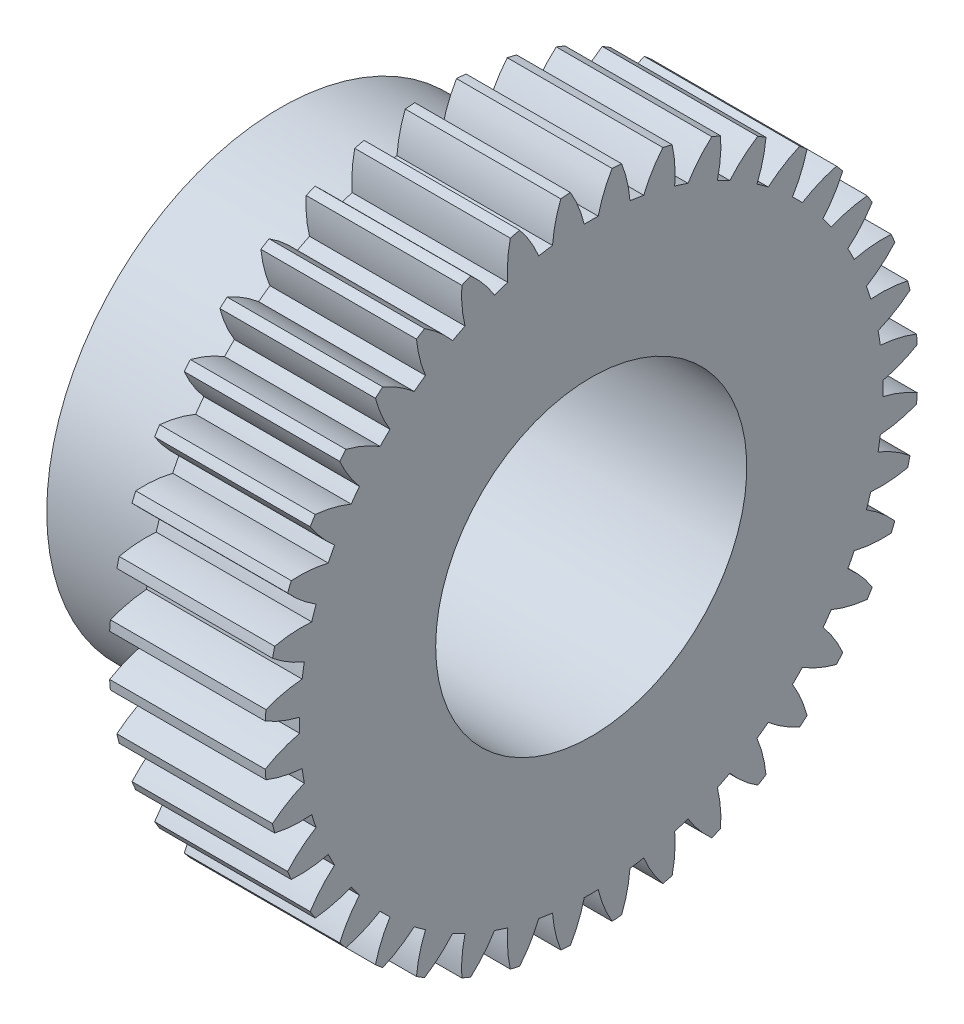
from build123d import *

# Parameters (mm, degrees)
BASPROSKE_W         = 10
BASPROSKE_H         = 21
TOOTHCUT_DEPTH      = 32.336879232
TEETHCUTS_COUNT     = 40
TEETHCUTS_ANGLE     = 351
HUBNEAONESKE_R      = 15
HUBNEARONE_DEPTH    = 40.0000508
BORSKE_R            = 10
BORE_DEPTH          = 10.0000508
SKETCH_1_R          = 32.883297891
CUT_EXTRUDE_1_DEPTH = 43.171205755


with BuildPart() as part:
    # BasProSke → Base-Revolve (revolve)
    with BuildSketch(Plane(origin=(0, 0, 0), x_dir=(1, 0, 0), z_dir=(0, 1, 0)), mode=Mode.PRIVATE) as base_revolve_sk:
        with Locations((5, 10.5)):
            Rectangle(BASPROSKE_W, BASPROSKE_H)
    revolve(base_revolve_sk.sketch.rotate(Axis((-10, 0, 0), (1, 0, 0)), 180), axis=Axis((-10, 0, 0), (1, 0, 0)))

    # TooCutSke → ToothCut (cut, through all)
    with BuildSketch(Plane(origin=(0, 0, 0), x_dir=(0, 0, -1), z_dir=(1, 0, 0))):
        with BuildLine():
            ThreePointArc((0.448673268, 18.74363074), (0, 18.749), (-0.448673268, 18.74363074))
            ThreePointArc((-0.448673268, 18.74363074), (-0.816786816, 19.89705013), (-1.354745081, 20.981708961))
            ThreePointArc((-1.354745081, 20.981708961), (0, 21.0254), (1.354745081, 20.981708961))
            ThreePointArc((1.354745081, 20.981708961), (0.816786816, 19.89705013), (0.448673268, 18.74363074))
        make_face()
    toothcut = extrude(amount=TOOTHCUT_DEPTH, mode=Mode.SUBTRACT)

    # TeethCuts: ToothCut ×40 about axis
    teethcuts_axis = Axis((-10, 0, 0), (1, 0, 0))
    for i in range(1, TEETHCUTS_COUNT):
        add(toothcut.rotate(teethcuts_axis, i * TEETHCUTS_ANGLE / (TEETHCUTS_COUNT - 1)), mode=Mode.SUBTRACT)

    # HubNeaOneSke → HubNearOne (add)
    with BuildSketch(Plane.ZY):
        with Locations(Location((0, 0, 0), (0, 0, 180))):
            Circle(HUBNEAONESKE_R)
    extrude(amount=HUBNEARONE_DEPTH)

    # BorSke → Bore (cut, symmetric)
    with BuildSketch(Plane(origin=(0, 0, 0), x_dir=(0, 0, -1), z_dir=(1, 0, 0))):
        with Locations(Location((0, 0, 0), (0, 0, 180))):
            Circle(BORSKE_R)
    extrude(amount=BORE_DEPTH, both=True, mode=Mode.SUBTRACT)

    # 草图1 → 切除-拉伸1 (cut, through all)
    with BuildSketch(Plane.ZY.offset(10)):
        Circle(SKETCH_1_R)
    extrude(amount=CUT_EXTRUDE_1_DEPTH, mode=Mode.SUBTRACT)


solid = part.part
